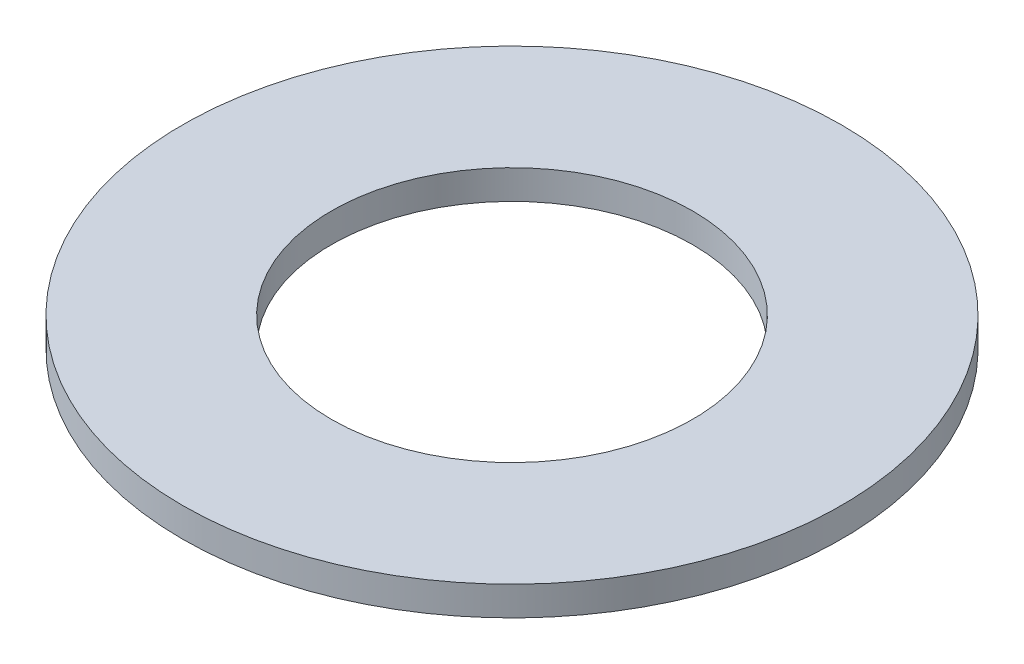
from build123d import *

# Parameters (mm, degrees)
SKETCH1_R           = 38.1
SKETCH1_R_2         = 20.8788
BOSS_EXTRUDE1_DEPTH = 3.3782


with BuildPart() as part:
    # Sketch1 → Boss-Extrude1 (new body)
    with BuildSketch(Plane(origin=(0, 0, 0), x_dir=(1, 0, 0), z_dir=(0, 1, 0))):
        Circle(SKETCH1_R)
        Circle(SKETCH1_R_2, mode=Mode.SUBTRACT)
    extrude(amount=BOSS_EXTRUDE1_DEPTH)


solid = part.part
